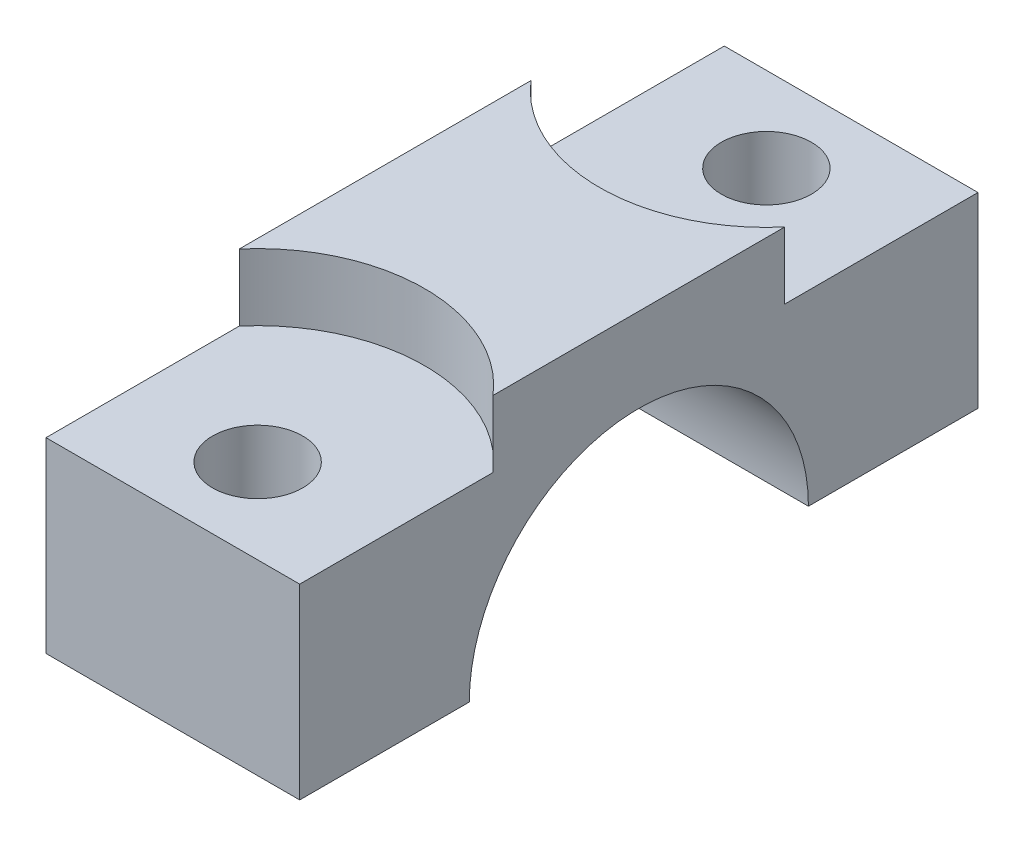
from build123d import *

# Parameters (mm, degrees)
BOSS_EXTRUDE1_DEPTH                           = 9.5
CBORE_FOR_M12_HEX_HEAD_CAP_SCREW1_D           = 6.75
CBORE_FOR_M12_HEX_HEAD_CAP_SCREW1_CBORE_D     = 25
CBORE_FOR_M12_HEX_HEAD_CAP_SCREW1_CBORE_DEPTH = 5


with BuildPart() as part:
    # Sketch2 → Boss-Extrude1 (new body, symmetric)
    with BuildSketch(Plane(origin=(0, 0, 0), x_dir=(0, 0, -1), z_dir=(1, 0, 0))):
        with BuildLine():
            Line((12.7, 0), (25.4, 0))
            Line((25.4, 0), (25.4, 19))
            Line((25.4, 19), (-25.4, 19))
            Line((-25.4, 19), (-25.4, 0))
            Line((-25.4, 0), (-12.7, 0))
            ThreePointArc((-12.7, 0), (0, 12.7), (12.7, 0))
        make_face()
    extrude(amount=BOSS_EXTRUDE1_DEPTH, both=True)

    # CBORE for M12 Hex Head Cap Screw1 (through all)
    with Locations(Plane(origin=(0, 19, 0), x_dir=(1, 0, 0), z_dir=(0, 1, 0))):
        with Locations((0, 19.05), (0, -19.05)):
            CounterBoreHole(CBORE_FOR_M12_HEX_HEAD_CAP_SCREW1_D / 2, CBORE_FOR_M12_HEX_HEAD_CAP_SCREW1_CBORE_D / 2, CBORE_FOR_M12_HEX_HEAD_CAP_SCREW1_CBORE_DEPTH)


solid = part.part
